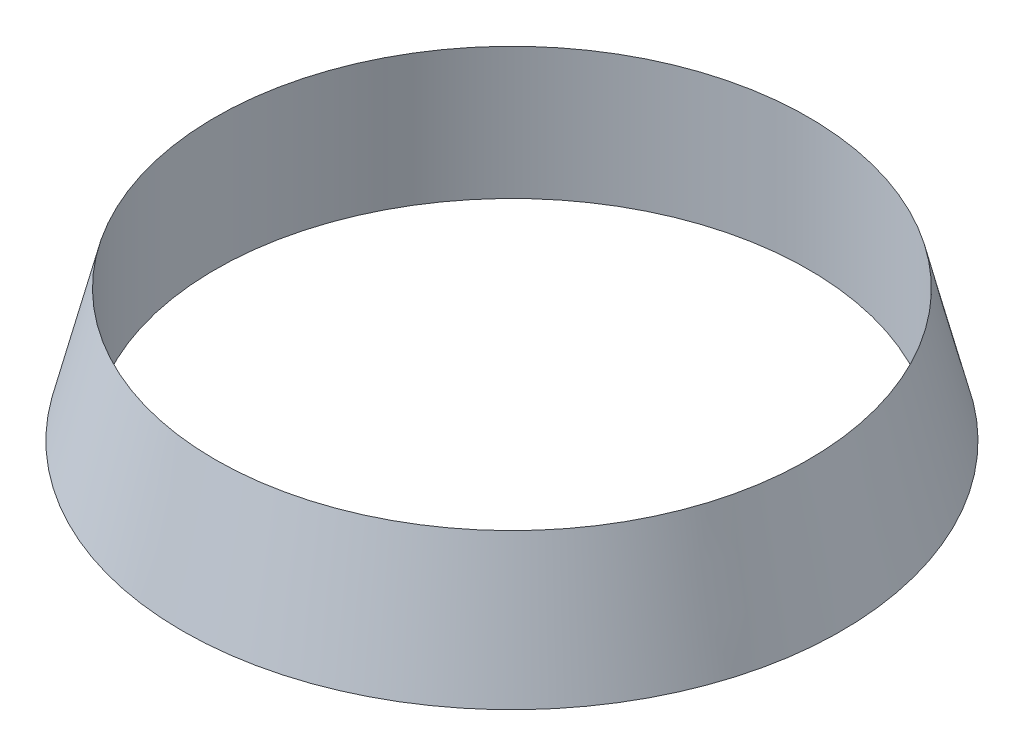
from build123d import *

# Parameters (mm, degrees)
SKETCH1_R          = 50
SKETCH2_R          = 45
SKETCH3_R          = 45
CUT_EXTRUDE1_DEPTH = 21.0000001


with BuildPart() as part:
    # Sketch1 → Loft1 section 0
    with BuildSketch(Plane(origin=(0, 0, 0), x_dir=(1, 0, 0), z_dir=(0, 1, 0))):
        Circle(SKETCH1_R)
    # Sketch2 → Loft1 section 1
    with BuildSketch(Plane(origin=(0, 20, 0), x_dir=(1, 0, 0), z_dir=(0, 1, 0))):
        Circle(SKETCH2_R)
    loft()

    # Sketch3 → Cut-Extrude1 (cut, through all)
    with BuildSketch(Plane(origin=(0, 20, 0), x_dir=(1, 0, 0), z_dir=(0, 1, 0))):
        Circle(SKETCH3_R)
    extrude(amount=-CUT_EXTRUDE1_DEPTH, mode=Mode.SUBTRACT)


solid = part.part
